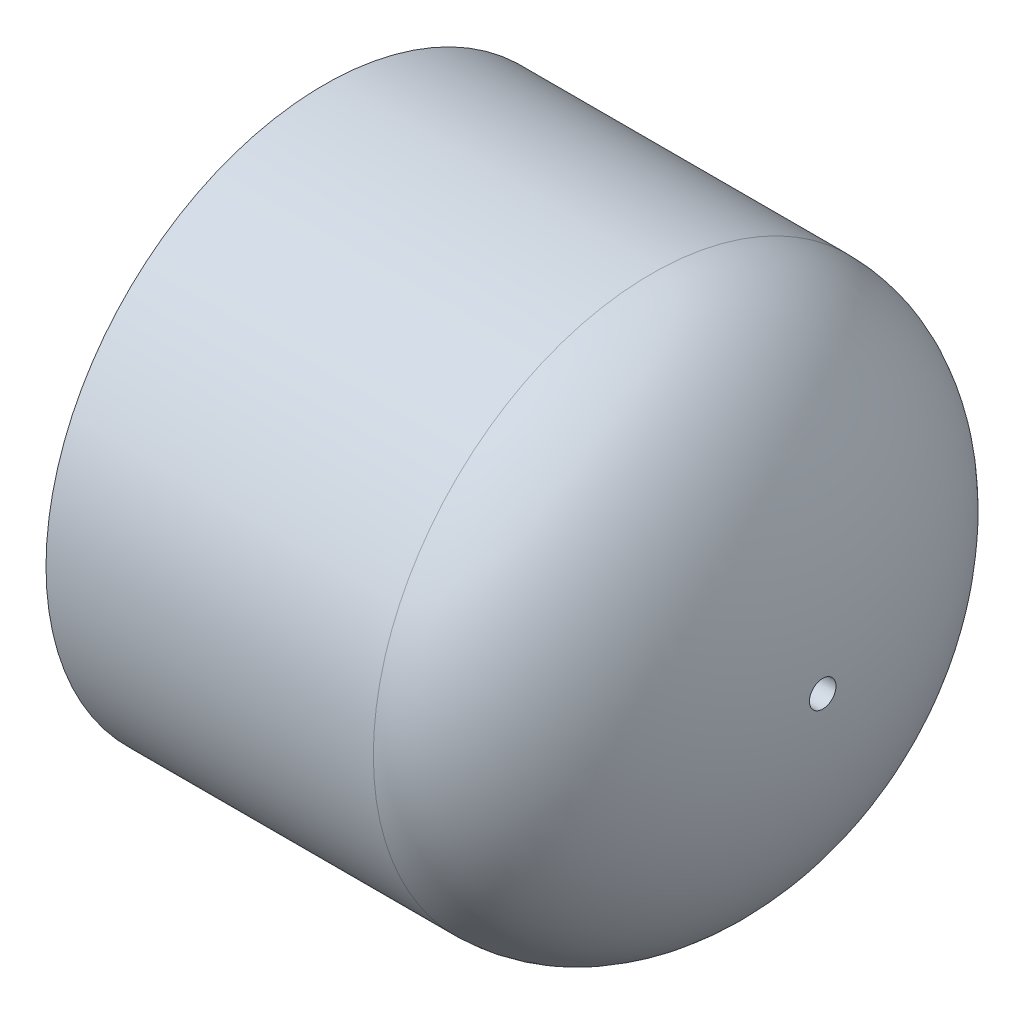
from build123d import *

# Parameters (mm, degrees)
SKETCH2_W = 1.35255
SKETCH2_H = 50.8


with BuildPart() as part:
    # Sketch1 → Revolve1 (revolve)
    with BuildSketch(Plane.XY):
        with BuildLine():
            Line((21.1328, 0), (25.4, 0))
            add(Edge.make_bspline(
                [(7.9375, -28.321), (25.4, -28.321), (25.4, 0)],
                knots=[3.141592654, 3.141592654, 3.141592654, 4.71238898, 4.71238898, 4.71238898], degree=2, weights=[1, 0.707106781, 1]))
            Line((7.9375, -28.321), (-25.4, -28.321))
            Line((-25.4, -28.321), (-25.4, -24.2824))
            Line((-25.4, -24.2824), (7.9375, -24.0538))
            add(Edge.make_bspline(
                [(7.9375, -24.0538), (21.1328, -24.0538), (21.1328, 0)],
                knots=[0, 0, 0, 1.570796327, 1.570796327, 1.570796327], degree=2, weights=[1, 0.707106781, 1]))
        make_face()
    revolve(axis=Axis((-25.4, 0, 0), (1, 0, 0)))

    # Sketch2 → #6-32 Tapped Hole1 (revolve, cut)
    with BuildSketch(Plane(origin=(-25.4, 0, 0), x_dir=(0, 0, 1), z_dir=(0, 1, 0))):
        with Locations((0.676275, 25.4)):
            Rectangle(SKETCH2_W, SKETCH2_H)
    revolve(axis=Axis((-31.75, 0, 0), (1, 0, 0)), mode=Mode.SUBTRACT)


solid = part.part
